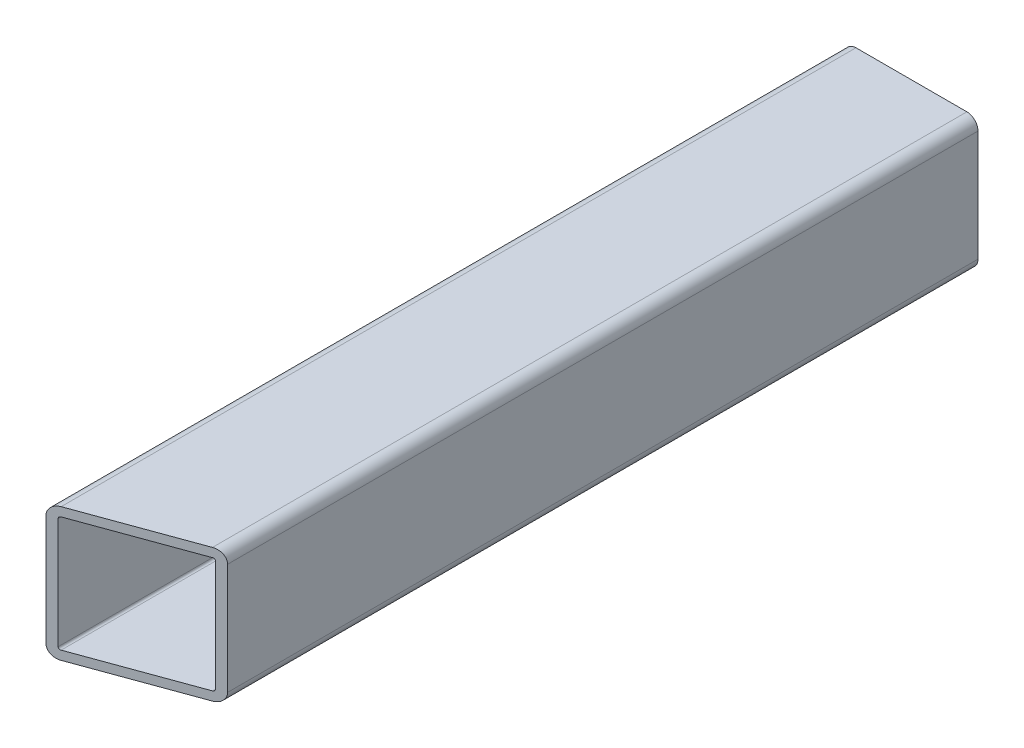
from build123d import *

# Parameters (mm, degrees)
EXTRUDE_THIN1_DEPTH     = 114.3
CUT_EXTRUDE1_DEPTH      = 1
CUT_EXTRUDE1_DEPTH_BACK = 39.1


with BuildPart() as part:
    # Sketch1 → Extrude-Thin1 (new body, symmetric)
    with BuildSketch(Plane.XY):
        with BuildLine():
            Line((-15.875, 19.05), (15.875, 19.05))
            ThreePointArc((15.875, 19.05), (18.12006403, 18.12006403), (19.05, 15.875))
            Line((19.05, 15.875), (19.05, -15.875))
            ThreePointArc((19.05, -15.875), (18.12006403, -18.12006403), (15.875, -19.05))
            Line((15.875, -19.05), (-15.875, -19.05))
            ThreePointArc((-15.875, -19.05), (-18.12006403, -18.12006403), (-19.05, -15.875))
            Line((-19.05, -15.875), (-19.05, 15.875))
            ThreePointArc((-19.05, 15.875), (-18.12006403, 18.12006403), (-15.875, 19.05))
        make_face()
        with BuildLine():
            Line((-15.875, 16.51), (15.875, 16.51))
            ThreePointArc((15.875, 16.51), (16.324012806, 16.324012806), (16.51, 15.875))
            Line((16.51, 15.875), (16.51, -15.875))
            ThreePointArc((16.51, -15.875), (16.324012806, -16.324012806), (15.875, -16.51))
            Line((15.875, -16.51), (-15.875, -16.51))
            ThreePointArc((-15.875, -16.51), (-16.324012806, -16.324012806), (-16.51, -15.875))
            Line((-16.51, -15.875), (-16.51, 15.875))
            ThreePointArc((-16.51, 15.875), (-16.324012806, 16.324012806), (-15.875, 16.51))
        make_face(mode=Mode.SUBTRACT)
    extrude(amount=EXTRUDE_THIN1_DEPTH, both=True)

    # Sketch3 → Cut-Extrude1 (cut, two sides)
    with BuildSketch(Plane(origin=(0, 19.05, 0), x_dir=(1, 0, 0), z_dir=(0, 1, 0))) as cut_extrude1_sk:
        Polygon((-464.000568463, -276.24876264), (-19.05, -114.3), (19.05, -100.432734074), (464.000568463, 61.516028566), (787.898093744, -828.38510836), (-140.103043182, -1166.149899566), align=None)
    extrude(amount=CUT_EXTRUDE1_DEPTH, mode=Mode.SUBTRACT)
    extrude(cut_extrude1_sk.sketch, amount=-CUT_EXTRUDE1_DEPTH_BACK, mode=Mode.SUBTRACT)


solid = part.part
